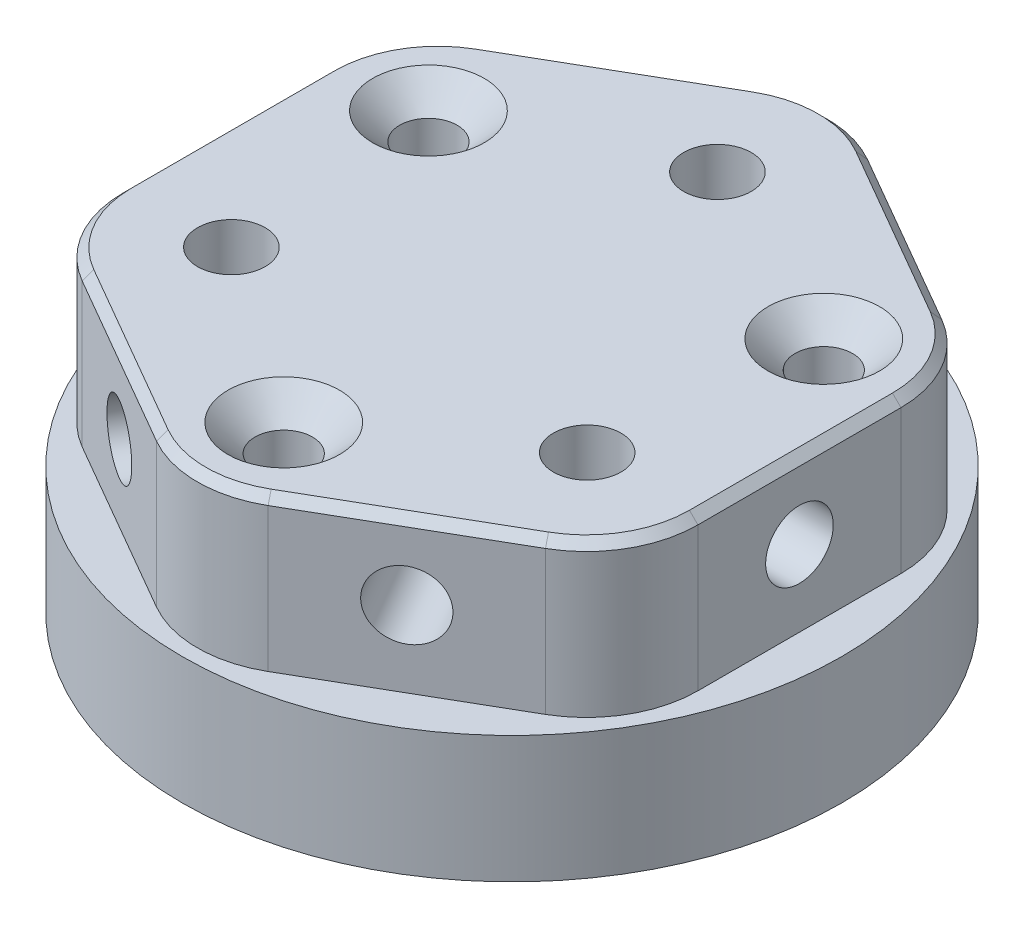
from build123d import *

# Parameters (mm, degrees)
SKETCH_9_R                = 19.5
SKETCH_9_R_2              = 2
SKETCH_9_R_3              = 1.5
EXTRUDE_1_DEPTH           = 7.5
EXTRUDE_2_DEPTH           = 12
SKETCH_15_R               = 2
CUT_EXTRUDE_2_DEPTH       = 10.637495374
CUT_EXTRUDE_2_DEPTH_BACK  = 44.637495374
SKETCH_16_R               = 2
CUT_EXTRUDE_3_DEPTH       = 10.637495374
CUT_EXTRUDE_3_DEPTH_BACK  = 44.637495374
SKETCH_17_R               = 2
CUT_EXTRUDE_4_DEPTH       = 3.5
CUT_EXTRUDE_4_DEPTH_BACK  = 37.5
EXTRUDE_3_DEPTH           = 19.5
SKETCH_19_R               = 1.5
SKETCH_19_R_2             = 2
CUT_EXTRUDE_5_DEPTH       = 8.5
CUT_EXTRUDE_5_DEPTH_BACK  = 13
HOLE_WIZARD_3_D           = 3.4
HOLE_WIZARD_3_CSINK_D     = 6.6
HOLE_WIZARD_3_CSINK_ANGLE = 90
CUT_EXTRUDE_6_DEPTH       = 3
CHAMFER_2_SIZE            = 0.5
HOLE_WIZARD_4_D           = 3.2
HOLE_WIZARD_4_CSINK_D     = 6.6
HOLE_WIZARD_4_CSINK_ANGLE = 90


with BuildPart() as part:
    # 草图9 → 凸台-拉伸1 (new body)
    with BuildSketch(Plane(origin=(0, 0, 0), x_dir=(1, 0, 0), z_dir=(0, 1, 0))):
        Circle(SKETCH_9_R)
        with Locations((0, 12.15)):
            Circle(SKETCH_9_R_2, mode=Mode.SUBTRACT)
        with Locations((-10.522208656, -6.075)):
            Circle(SKETCH_9_R_2, mode=Mode.SUBTRACT)
        with Locations((10.522208656, -6.075)):
            Circle(SKETCH_9_R_2, mode=Mode.SUBTRACT)
        with Locations((-11.691342951, 6.75)):
            Circle(SKETCH_9_R_3, mode=Mode.SUBTRACT)
        with Locations((0, -13.5)):
            Circle(SKETCH_9_R_3, mode=Mode.SUBTRACT)
        with Locations((11.691342951, 6.75)):
            Circle(SKETCH_9_R_3, mode=Mode.SUBTRACT)
    extrude(amount=EXTRUDE_1_DEPTH)

    # 草图13 → 凸台-拉伸2 (add)
    with BuildSketch(Plane(origin=(0, 7.5, 0), x_dir=(1, 0, 0), z_dir=(0, 1, 0))):
        with BuildLine():
            Line((-13.7, -11.720210465), (-3.3, -17.724653264))
            ThreePointArc((-3.3, -17.724653264), (0, -18.608885599), (3.3, -17.724653264))
            Line((3.3, -17.724653264), (13.7, -11.720210465))
            ThreePointArc((13.7, -11.720210465), (16.115767665, -9.3044428), (17, -6.0044428))
            Line((17, -6.0044428), (17, 6.0044428))
            ThreePointArc((17, 6.0044428), (16.115767665, 9.3044428), (13.7, 11.720210465))
            Line((13.7, 11.720210465), (3.3, 17.724653264))
            ThreePointArc((3.3, 17.724653264), (0, 18.608885599), (-3.3, 17.724653264))
            Line((-3.3, 17.724653264), (-13.7, 11.720210465))
            ThreePointArc((-13.7, 11.720210465), (-16.115767665, 9.3044428), (-17, 6.0044428))
            Line((-17, 6.0044428), (-17, -6.0044428))
            ThreePointArc((-17, -6.0044428), (-16.115767665, -9.3044428), (-13.7, -11.720210465))
        make_face()
    extrude(amount=EXTRUDE_2_DEPTH)

    # 草图15 → 切除-拉伸2 (cut, two sides)
    with BuildSketch(Plane(origin=(-8.5, 0, -14.722431864), x_dir=(-0.866025404, 0, 0.5), z_dir=(-0.5, 0, -0.866025404))) as cut_extrude_2_sk:
        with Locations((0, 12)):
            Circle(SKETCH_15_R)
    extrude(amount=CUT_EXTRUDE_2_DEPTH, mode=Mode.SUBTRACT)
    extrude(cut_extrude_2_sk.sketch, amount=-CUT_EXTRUDE_2_DEPTH_BACK, mode=Mode.SUBTRACT)

    # 草图16 → 切除-拉伸3 (cut, two sides)
    with BuildSketch(Plane(origin=(8.5, 0, -14.722431864), x_dir=(-0.866025404, 0, -0.5), z_dir=(0.5, 0, -0.866025404))) as cut_extrude_3_sk:
        with Locations((0, 12)):
            Circle(SKETCH_16_R)
    extrude(amount=CUT_EXTRUDE_3_DEPTH, mode=Mode.SUBTRACT)
    extrude(cut_extrude_3_sk.sketch, amount=-CUT_EXTRUDE_3_DEPTH_BACK, mode=Mode.SUBTRACT)

    # 草图17 → 切除-拉伸4 (cut, two sides)
    with BuildSketch(Plane(origin=(17, 0, 0), x_dir=(0, 0, -1), z_dir=(1, 0, 0))) as cut_extrude_4_sk:
        with Locations((0, 12)):
            Circle(SKETCH_17_R)
    extrude(amount=CUT_EXTRUDE_4_DEPTH, mode=Mode.SUBTRACT)
    extrude(cut_extrude_4_sk.sketch, amount=-CUT_EXTRUDE_4_DEPTH_BACK, mode=Mode.SUBTRACT)

    # 草图18 → 凸台-拉伸3 (add)
    with BuildSketch(Plane(origin=(0, 19.5, 0), x_dir=(1, 0, 0), z_dir=(0, 1, 0))):
        Polygon((-7, -4.041451884), (0, -8.082903769), (7, -4.041451884), (7, 4.041451884), (0, 8.082903769), (-7, 4.041451884), align=None)
    extrude(amount=-EXTRUDE_3_DEPTH)

    # 草图19 → 切除-拉伸5 (cut, two sides)
    with BuildSketch(Plane.XZ.offset(-7.5)) as cut_extrude_5_sk:
        with Locations((-11.691342951, -6.75)):
            Circle(SKETCH_19_R)
        with Locations((-10.522208656, 6.075)):
            Circle(SKETCH_19_R_2)
        with Locations((0, 13.5)):
            Circle(SKETCH_19_R)
        with Locations((10.522208656, 6.075)):
            Circle(SKETCH_19_R_2)
        with Locations((11.691342951, -6.75)):
            Circle(SKETCH_19_R)
        with Locations((0, -12.15)):
            Circle(SKETCH_19_R_2)
    extrude(amount=CUT_EXTRUDE_5_DEPTH, mode=Mode.SUBTRACT)
    extrude(cut_extrude_5_sk.sketch, amount=-CUT_EXTRUDE_5_DEPTH_BACK, mode=Mode.SUBTRACT)

    # 打孔尺寸(%根据十字)槽沉头木螺钉的类型3 (through all)
    with Locations(Plane(origin=(0, 19.5, 0), x_dir=(1, 0, 0), z_dir=(0, 1, 0))):
        with Locations((11.691342951, 6.75), (0, -13.5), (-11.691342951, 6.75)):
            CounterSinkHole(HOLE_WIZARD_3_D / 2, HOLE_WIZARD_3_CSINK_D / 2, counter_sink_angle=HOLE_WIZARD_3_CSINK_ANGLE)

    # 草图26 → 切除-拉伸6 (cut)
    with BuildSketch(Plane(origin=(0, 19.5, 0), x_dir=(1, 0, 0), z_dir=(0, 1, 0))):
        with BuildLine():
            Line((17, -6.0044428), (17, 6.0044428))
            ThreePointArc((17, 6.0044428), (16.115767665, 9.3044428), (13.7, 11.720210465))
            Line((13.7, 11.720210465), (3.3, 17.724653264))
            ThreePointArc((3.3, 17.724653264), (0, 18.608885599), (-3.3, 17.724653264))
            Line((-3.3, 17.724653264), (-13.7, 11.720210465))
            ThreePointArc((-13.7, 11.720210465), (-16.115767665, 9.3044428), (-17, 6.0044428))
            Line((-17, 6.0044428), (-17, -6.0044428))
            ThreePointArc((-17, -6.0044428), (-16.115767665, -9.3044428), (-13.7, -11.720210465))
            Line((-13.7, -11.720210465), (-3.3, -17.724653264))
            ThreePointArc((-3.3, -17.724653264), (0, -18.608885599), (3.3, -17.724653264))
            Line((3.3, -17.724653264), (13.7, -11.720210465))
            ThreePointArc((13.7, -11.720210465), (16.115767665, -9.3044428), (17, -6.0044428))
        make_face()
    extrude(amount=-CUT_EXTRUDE_6_DEPTH, mode=Mode.SUBTRACT)

    # 倒角2
    chamfer_2_edges = [part.edges().sort_by_distance(p)[0] for p in [
        (16.115767665, 16.5, 9.3044428),
        (8.5, 16.5, 14.722431864),
        (0, 16.5, 18.608885599),
        (-8.5, 16.5, 14.722431864),
        (-16.115767665, 16.5, 9.3044428),
        (-17, 16.5, 0),
        (-16.115767665, 16.5, -9.3044428),
        (-8.5, 16.5, -14.722431864),
        (0, 16.5, -18.608885599),
        (8.5, 16.5, -14.722431864),
        (16.115767665, 16.5, -9.3044428),
        (17, 16.5, 0),
    ]]
    chamfer(chamfer_2_edges, length=CHAMFER_2_SIZE)

    # 打孔尺寸(%根据十字)槽沉头木螺钉的类型4 (through all)
    with Locations(Plane(origin=(0, 16.5, 0), x_dir=(1, 0, 0), z_dir=(0, 1, 0))):
        with Locations((0, -13.5), (11.691342951, 6.75), (-11.691342951, 6.75)):
            CounterSinkHole(HOLE_WIZARD_4_D / 2, HOLE_WIZARD_4_CSINK_D / 2, counter_sink_angle=HOLE_WIZARD_4_CSINK_ANGLE)


solid = part.part
